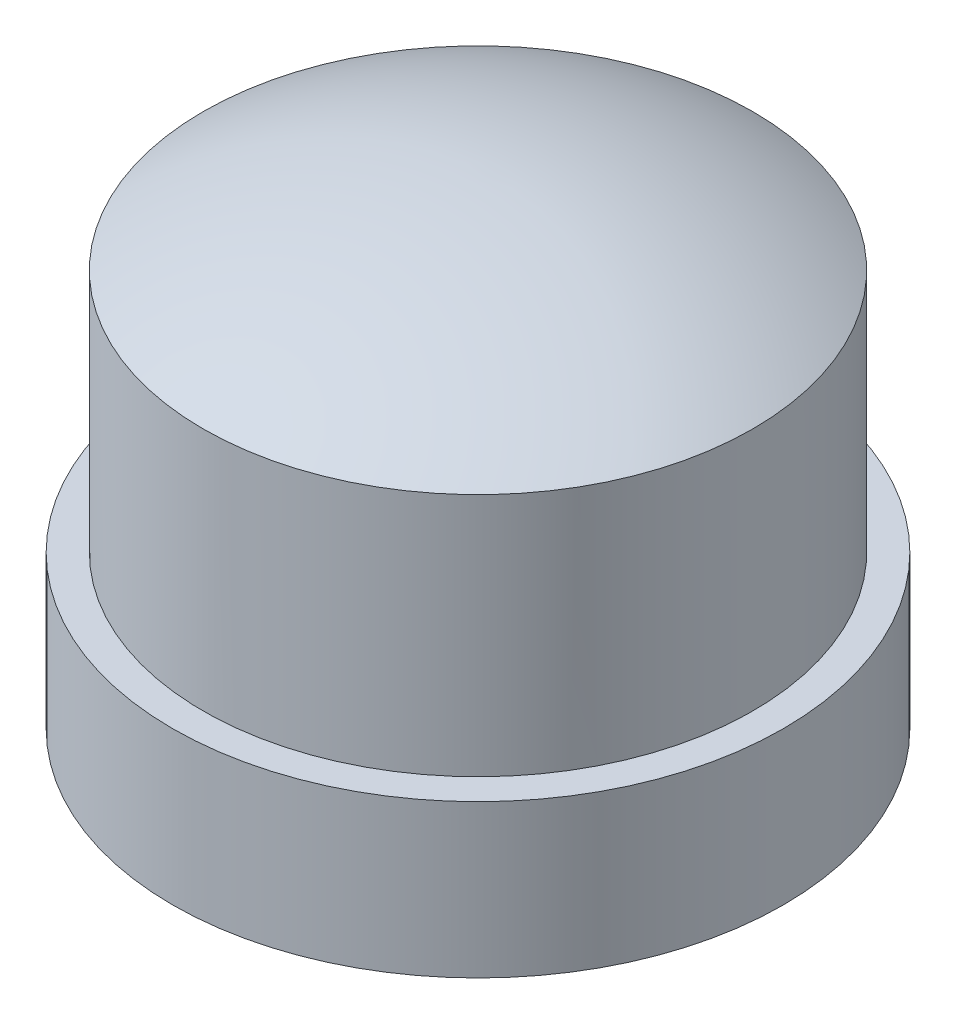
from build123d import *

# Parameters (mm, degrees)
SKETCH1_R           = 10
BOSS_EXTRUDE1_DEPTH = 5


with BuildPart() as part:
    # Sketch1 → Boss-Extrude1 (new body)
    with BuildSketch(Plane(origin=(0, 0, 0), x_dir=(1, 0, 0), z_dir=(0, 1, 0))):
        Circle(SKETCH1_R)
    extrude(amount=BOSS_EXTRUDE1_DEPTH)

    # Sketch2 → Revolve1 (revolve)
    with BuildSketch(Plane(origin=(0, 0, 0), x_dir=(0, 0, -1), z_dir=(1, 0, 0))):
        with BuildLine():
            Line((-9, 13), (-9, 5))
            Line((-9, 5), (0, 5))
            Line((0, 5), (0, 15.5))
            ThreePointArc((0, 15.5), (-4.670385423, 14.863387523), (-9, 13))
        make_face()
    revolve(axis=Axis((0, 5, 0), (0, 1, 0)))


solid = part.part
